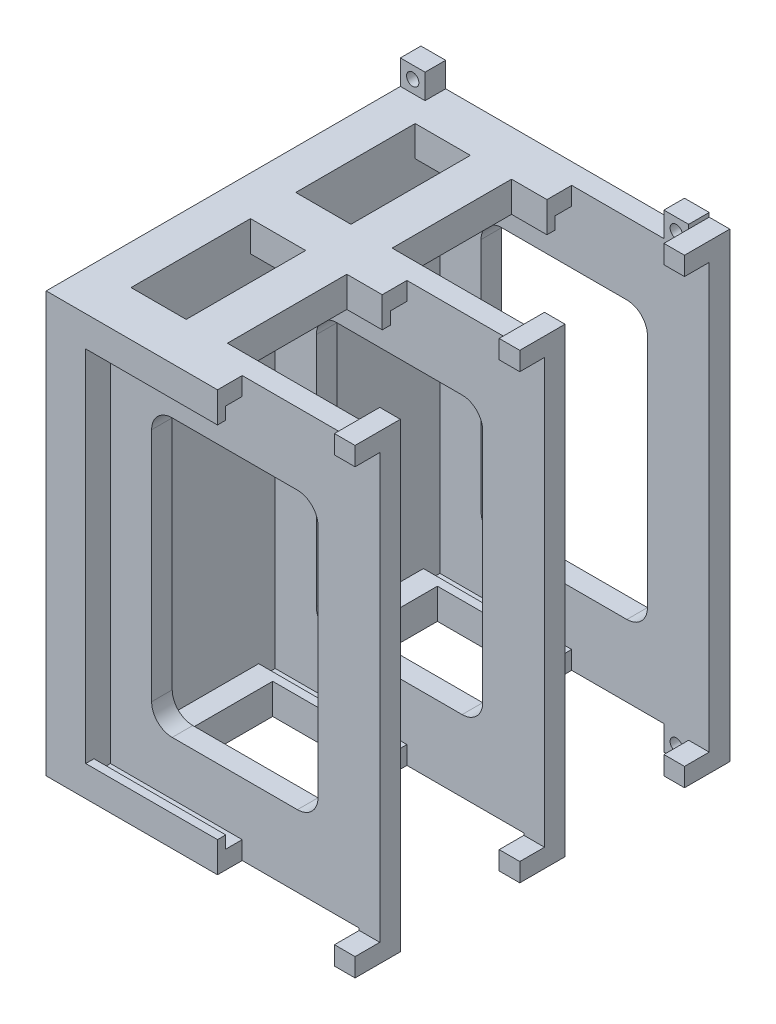
from build123d import *

# Parameters (mm, degrees)
BOSS_EXTRUDE1_DEPTH     = 5
SKETCH4_W               = 5
SKETCH4_H               = 4.5
BOSS_EXTRUDE2_DEPTH     = 6
SKETCH5_W               = 3
SKETCH5_H               = 2
BOSS_EXTRUDE3_DEPTH     = 32
SKETCH6_W               = 6
SKETCH6_H               = 6
BOSS_EXTRUDE4_DEPTH     = 5
BOSS_EXTRUDE4_2_DEPTH   = 5
BOSS_EXTRUDE4_3_DEPTH   = 5
BOSS_EXTRUDE4_4_DEPTH   = 5
SKETCH7_R               = 1.5
CUT_EXTRUDE1_DEPTH      = 6
LPATTERN1_COUNT         = 3
LPATTERN1_PITCH         = 40
SKETCH8_W               = 10
SKETCH8_H               = 7.4
BOSS_EXTRUDE5_DEPTH     = 29
SKETCH9_W               = 10
SKETCH9_H               = 7.4
BOSS_EXTRUDE6_DEPTH     = 29
CUT_EXTRUDE2_DEPTH      = 7
CUT_EXTRUDE2_DEPTH_BACK = 86


with BuildPart() as part:
    # Sketch1 → Boss-Extrude1 (new body)
    with BuildSketch(Plane(origin=(0, 0, 0), x_dir=(0, 1, 0), z_dir=(0, 0, 1))):
        Polygon((-51, 5), (-51, 75), (51, 75), (51, 5), (56, 5), (56, 0), (-56, 0), (-56, 5), align=None)
    extrude(amount=BOSS_EXTRUDE1_DEPTH)

    # Sketch4 → Boss-Extrude2 (add)
    with BuildSketch(Plane.XY.offset(5)):
        Polygon((-75, 51), (-75, -51), (-33.4, -51), (-33.4, -46.6), (-65.4, -46.6), (-65.4, 46.6), (-33.4, 46.6), (-33.4, 51), align=None)
        with Locations((-2.5, 53.75)):
            Rectangle(SKETCH4_W, SKETCH4_H)
        with Locations((-2.5, -53.75)):
            Rectangle(SKETCH4_W, SKETCH4_H)
    extrude(amount=BOSS_EXTRUDE2_DEPTH)

    # Sketch5 → Boss-Extrude3 (add)
    with BuildSketch(Plane.YZ.offset(-65.4)):
        with Locations((-45.1, 10)):
            Rectangle(SKETCH5_W, SKETCH5_H)
        with Locations((45.1, 10)):
            Rectangle(SKETCH5_W, SKETCH5_H)
    extrude(amount=BOSS_EXTRUDE3_DEPTH)


with BuildPart() as body_2:
    # Sketch6 → Boss-Extrude4 (new body)
    with BuildSketch(Plane(origin=(0, 0, 0), x_dir=(1, 0, 0), z_dir=(0, 0, -1))):
        with Locations((-8, 54)):
            Rectangle(SKETCH6_W, SKETCH6_H)
    extrude(amount=-BOSS_EXTRUDE4_DEPTH)


with BuildPart() as body_3:
    # Sketch6 → Boss-Extrude4 2 (new body)
    with BuildSketch(Plane(origin=(0, 0, 0), x_dir=(1, 0, 0), z_dir=(0, 0, -1))):
        with Locations((-72, 54)):
            Rectangle(SKETCH6_W, SKETCH6_H)
    extrude(amount=-BOSS_EXTRUDE4_2_DEPTH)


with BuildPart() as body_4:
    # Sketch6 → Boss-Extrude4 3 (new body)
    with BuildSketch(Plane(origin=(0, 0, 0), x_dir=(1, 0, 0), z_dir=(0, 0, -1))):
        with Locations((-8, -54)):
            Rectangle(SKETCH6_W, SKETCH6_H)
    extrude(amount=-BOSS_EXTRUDE4_3_DEPTH)


with BuildPart() as body_5:
    # Sketch6 → Boss-Extrude4 4 (new body)
    with BuildSketch(Plane(origin=(0, 0, 0), x_dir=(1, 0, 0), z_dir=(0, 0, -1))):
        with Locations((-72, -54)):
            Rectangle(SKETCH6_W, SKETCH6_H)
    extrude(amount=-BOSS_EXTRUDE4_4_DEPTH)


with BuildPart() as cut_extrude1_tool:
    # Sketch7 → Cut-Extrude1 (new body, through all)
    with BuildSketch(Plane.XY.offset(5)):
        with Locations((-8, -54)):
            Circle(SKETCH7_R)
        with Locations((-72, -54)):
            Circle(SKETCH7_R)
        with Locations((-8, 54)):
            Circle(SKETCH7_R)
        with Locations((-72, 54)):
            Circle(SKETCH7_R)
    extrude(amount=-CUT_EXTRUDE1_DEPTH)


with BuildPart() as body_2_1:
    add(body_2.part)

    # Cut-Extrude1: cut by cut_extrude1_tool
    add(cut_extrude1_tool.part, mode=Mode.SUBTRACT)


with BuildPart() as body_3_1:
    add(body_3.part)

    # Cut-Extrude1: cut by cut_extrude1_tool
    add(cut_extrude1_tool.part, mode=Mode.SUBTRACT)


with BuildPart() as body_4_1:
    add(body_4.part)

    # Cut-Extrude1: cut by cut_extrude1_tool
    add(cut_extrude1_tool.part, mode=Mode.SUBTRACT)


with BuildPart() as body_5_1:
    add(body_5.part)

    # Cut-Extrude1: cut by cut_extrude1_tool
    add(cut_extrude1_tool.part, mode=Mode.SUBTRACT)


with BuildPart() as lpattern1_1:
    # LPattern1: pattern copy
    add(part.part.moved(Location(Vector(0, 0, 1) * (1 * LPATTERN1_PITCH))))



with BuildPart() as lpattern1_2:
    # LPattern1: pattern copy
    add(part.part.moved(Location(Vector(0, 0, 1) * (2 * LPATTERN1_PITCH))))


with BuildPart() as part_1:
    add(part.part)

    # Sketch8 → Boss-Extrude5 (add)
    with BuildSketch(Plane.XY.offset(11)):
        with Locations((-47, 47.3)):
            Rectangle(SKETCH8_W, SKETCH8_H)
        Polygon((-65.4, 51), (-65.4, -43.6), (-60, -43.6), (-60, -51), (-75, -51), (-75, 51), align=None)
    extrude(amount=BOSS_EXTRUDE5_DEPTH)


with BuildPart() as lpattern1_1_1:
    add(lpattern1_1.part)

    add(lpattern1_2.part)  # Boss-Extrude6 merges LPattern1_2
    # Sketch9 → Boss-Extrude6 (add)
    with BuildSketch(Plane.XY.offset(51)):
        with Locations((-47, 47.3)):
            Rectangle(SKETCH9_W, SKETCH9_H)
        Polygon((-65.4, 51), (-65.4, -43.6), (-60, -43.6), (-60, -51), (-75, -51), (-75, 51), align=None)
    extrude(amount=BOSS_EXTRUDE6_DEPTH)

    # Combine1: union part, body 3, body 2, body 5, body 4
    add(part_1.part)
    add(body_3_1.part)
    add(body_2_1.part)
    add(body_5_1.part)
    add(body_4_1.part)

    # Sketch10 → Cut-Extrude2 (cut, two sides)
    with BuildSketch(Plane.XY.offset(85)) as cut_extrude2_sk:
        with BuildLine():
            Line((-50.4, 33.6), (-20, 33.6))
            ThreePointArc((-20, 33.6), (-16.464466094, 32.135533906), (-15, 28.6))
            Line((-15, 28.6), (-15, -28.6))
            ThreePointArc((-15, -28.6), (-16.464466094, -32.135533906), (-20, -33.6))
            Line((-20, -33.6), (-50.4, -33.6))
            ThreePointArc((-50.4, -33.6), (-53.935533906, -32.135533906), (-55.4, -28.6))
            Line((-55.4, -28.6), (-55.4, 28.6))
            ThreePointArc((-55.4, 28.6), (-53.935533906, 32.135533906), (-50.4, 33.6))
        make_face()
    extrude(amount=CUT_EXTRUDE2_DEPTH, mode=Mode.SUBTRACT)
    extrude(cut_extrude2_sk.sketch, amount=-CUT_EXTRUDE2_DEPTH_BACK, mode=Mode.SUBTRACT)


solid = lpattern1_1_1.part
